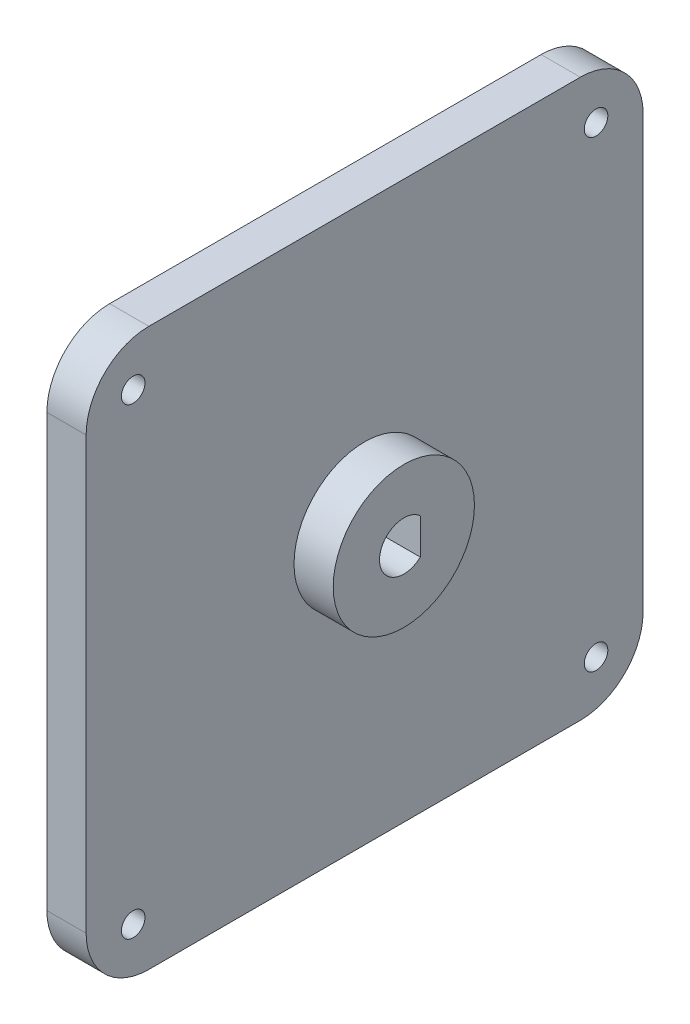
from build123d import *

# Parameters (mm, degrees)
SKETCH1_W           = 71
SKETCH1_H           = 71
SKETCH1_R           = 1.5
BOSS_EXTRUDE1_DEPTH = 5
FILLET1_R           = 8
SKETCH2_R           = 9
BOSS_EXTRUDE2_DEPTH = 5
CUT_EXTRUDE1_DEPTH  = 11


with BuildPart() as part:
    # Sketch1 → Boss-Extrude1 (new body)
    with BuildSketch(Plane(origin=(0, 0, 0), x_dir=(0, 0, -1), z_dir=(1, 0, 0))):
        with Locations((35.5, 35.5)):
            Rectangle(SKETCH1_W, SKETCH1_H)
        with Locations((6, 6)):
            Circle(SKETCH1_R, mode=Mode.SUBTRACT)
        with Locations((6, 65)):
            Circle(SKETCH1_R, mode=Mode.SUBTRACT)
        with Locations((65, 65)):
            Circle(SKETCH1_R, mode=Mode.SUBTRACT)
        with Locations((65, 6)):
            Circle(SKETCH1_R, mode=Mode.SUBTRACT)
    extrude(amount=BOSS_EXTRUDE1_DEPTH)

    # Fillet1
    fillet1_edges = [part.edges().sort_by_distance(p)[0] for p in [
        (2.5, 71, 0),
        (2.5, 71, -71),
        (2.5, 0, -71),
        (2.5, 0, 0),
    ]]
    fillet(fillet1_edges, radius=FILLET1_R)

    # Sketch2 → Boss-Extrude2 (add)
    with BuildSketch(Plane(origin=(5, 0, 0), x_dir=(0, 0, -1), z_dir=(1, 0, 0))):
        with Locations((35.5, 35.5)):
            Circle(SKETCH2_R)
    extrude(amount=BOSS_EXTRUDE2_DEPTH)

    # Sketch3 → Cut-Extrude1 (cut, through all)
    with BuildSketch(Plane(origin=(10, 0, 0), x_dir=(0, 0, -1), z_dir=(1, 0, 0))):
        with BuildLine():
            Line((37.6, 33.21964915), (37.6, 37.78035085))
            ThreePointArc((37.6, 37.78035085), (32.4, 35.5), (37.6, 33.21964915))
        make_face()
    extrude(amount=-CUT_EXTRUDE1_DEPTH, mode=Mode.SUBTRACT)


solid = part.part
